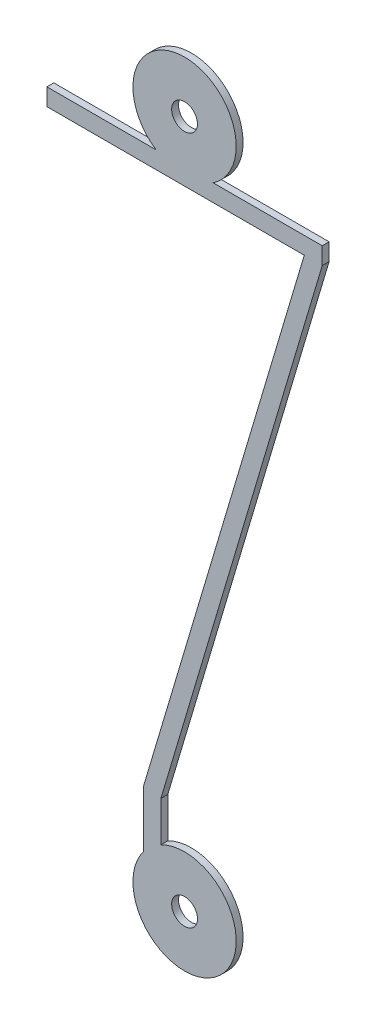
from build123d import *

# Parameters (mm, degrees)
SKETCH1_R           = 0.375
BOSS_EXTRUDE1_DEPTH = 0.1


with BuildPart() as part:
    # Sketch1 → Boss-Extrude1 (new body, symmetric)
    with BuildSketch(Plane.XY):
        with BuildLine():
            Line((-4, 8.75), (-0.829156198, 8.75))
            ThreePointArc((-0.829156198, 8.75), (0, 11.5), (0.829156198, 8.75))
            Line((0.829156198, 8.75), (4, 8.75))
            Line((4, 8.75), (4, 8.25))
            Line((4, 8.25), (-0.6875, -7.5))
            Line((-0.6875, -7.5), (-0.6875, -8.666829437))
            ThreePointArc((-0.6875, -8.666829437), (0.960377242, -11.152248043), (-1.1875, -9.083570106))
            Line((-1.1875, -9.083570106), (-1.1875, -7.427173711))
            Line((-1.1875, -7.427173711), (3.478325509, 8.25))
            Line((3.478325509, 8.25), (-4, 8.25))
            Line((-4, 8.25), (-4, 8.75))
        make_face()
        with Locations((0, 10)):
            Circle(SKETCH1_R, mode=Mode.SUBTRACT)
        with Locations((0, -10)):
            Circle(SKETCH1_R, mode=Mode.SUBTRACT)
    extrude(amount=BOSS_EXTRUDE1_DEPTH, both=True)


solid = part.part
